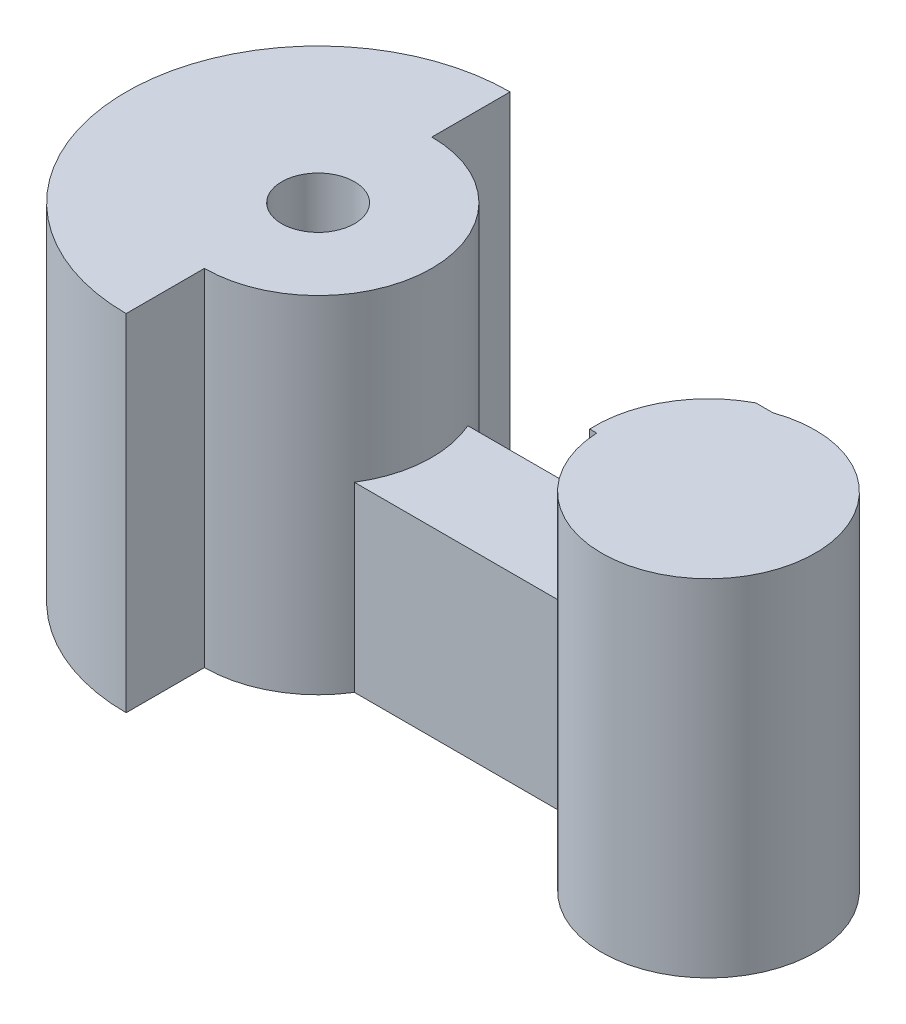
from build123d import *
from build123d.topology import SkipClean

# Parameters (mm, degrees)
BOSS_EXTRUDE3_DEPTH      = 4.826
BOSS_EXTRUDE3_DEPTH_BACK = 4.826
SKETCH1_R                = 1.016
CUT_EXTRUDE1_START       = -4.572
CUT_EXTRUDE1_DEPTH       = 4.572


with BuildPart() as part:
    # Sketch1 → Boss-Extrude3 (new, two sides: drawn at the far end of the back side and taken through both)
    with BuildSketch(Plane(origin=(0, 0, 0), x_dir=(1, 0, 0), z_dir=(0, 1, 0)).offset(-BOSS_EXTRUDE3_DEPTH_BACK)):
        with BuildLine():
            Line((5.7179716, 2.345697152), (5.7179716, 4.530275324))
            ThreePointArc((5.7179716, 4.530275324), (0.358393428, -0.829302848), (5.7179716, -6.18888102))
            Line((5.7179716, -6.18888102), (5.7179716, -4.004302848))
            ThreePointArc((5.7179716, -4.004302848), (7.258416359, -3.605569216), (8.411946387, -2.509518561))
            Line((8.411946387, -2.509518561), (15.174656113, -2.509518561))
            ThreePointArc((15.174656113, -2.509518561), (20.628265967, -4.022228083), (17.1479716, 0.440697152))
            Line((17.1479716, 0.440697152), (8.627907166, 0.440697152))
            ThreePointArc((8.627907166, 0.440697152), (7.45699072, 1.827092736), (5.7179716, 2.345697152))
        make_face()
        with Locations((5.7179716, -0.829302848)):
            Circle(SKETCH1_R, mode=Mode.SUBTRACT)
    extrude(amount=BOSS_EXTRUDE3_DEPTH + BOSS_EXTRUDE3_DEPTH_BACK)

    # Sketch4 → Cut-Extrude1 (cut)
    with SkipClean():  # the faces are left unmerged after this step: merging them gives an invalid solid
        with BuildSketch(Plane(origin=(0, 4.826, 0), x_dir=(1, 0, 0), z_dir=(0, 1, 0)).offset(CUT_EXTRUDE1_START)):
            with BuildLine():
                ThreePointArc((8.8929716, -0.829302848), (8.77034731, -1.703160688), (8.411946387, -2.509518561))
                Line((8.411946387, -2.509518561), (14.979501919, -2.509518561))
                ThreePointArc((14.979501919, -2.509518561), (15.394757752, -0.789817872), (16.665836289, 0.440697152))
                Line((16.665836289, 0.440697152), (8.627907166, 0.440697152))
                ThreePointArc((8.627907166, 0.440697152), (8.825999143, -0.180619729), (8.8929716, -0.829302848))
            make_face()
        extrude(amount=CUT_EXTRUDE1_DEPTH, mode=Mode.SUBTRACT)


solid = part.part
